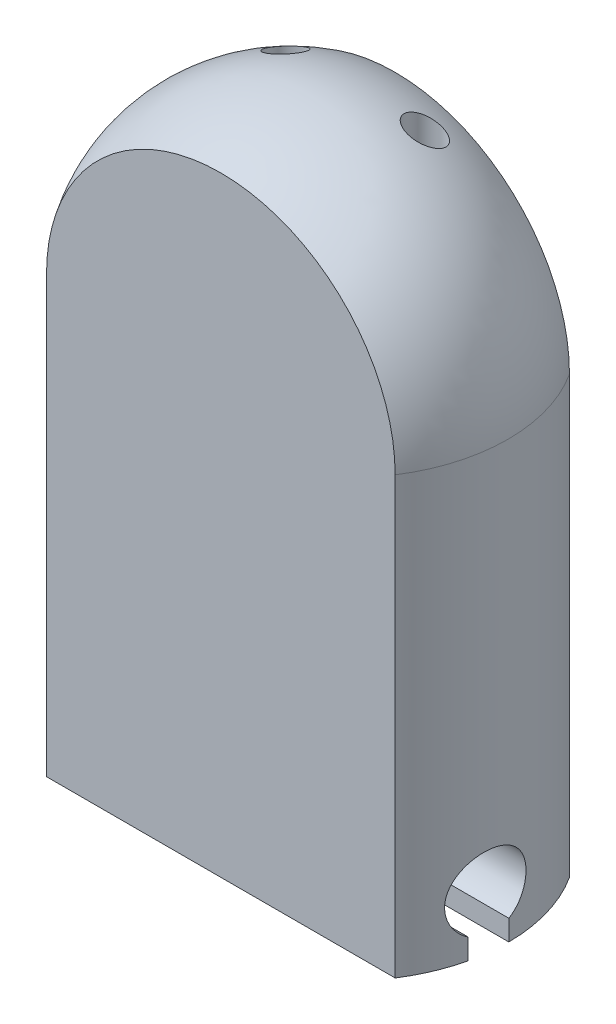
from build123d import *

# Parameters (mm, degrees)
BOSS_EXTRUDE1_DEPTH      = 10
BOSS_EXTRUDE2_DEPTH      = 25
SKETCH11_R               = 1
CUT_EXTRUDE9_DEPTH       = 40.519896768
CUT_EXTRUDE16_DEPTH      = 14.1
CUT_EXTRUDE16_DEPTH_BACK = 14.1


with BuildPart() as part:
    # Sketch1 → Boss-Extrude1 (new body)
    with BuildSketch(Plane.XY):
        with BuildLine():
            Line((10, 0), (-10, 0))
            Line((-10, 0), (-10, 25))
            ThreePointArc((-10, 25), (0, 35), (10, 25))
            Line((10, 25), (10, 0))
        make_face()
    extrude(amount=BOSS_EXTRUDE1_DEPTH)

    # Sketch16 → Boss-Extrude2 (add)
    with BuildSketch(Plane.XZ):
        with BuildLine():
            Line((-10, 0), (-10, 10))
            ThreePointArc((-10, 10), (-11.472090345, 5), (-10, 0))
        make_face()
        with BuildLine():
            Line((10, 0), (10, 10))
            ThreePointArc((10, 10), (11.472090345, 5), (10, 0))
        make_face()
    extrude(amount=-BOSS_EXTRUDE2_DEPTH)

    # Sketch18 → Revolve1 (revolve)
    with BuildSketch(Plane(origin=(0, 25, 0), x_dir=(1, 0, 0), z_dir=(0, 1, 0))):
        with BuildLine():
            Line((10, 0), (10, -10))
            ThreePointArc((10, -10), (11.472090345, -5), (10, 0))
        make_face()
    revolve(axis=Axis((0, 25, 0), (0, 0, 1)))

    # Sketch11 → Cut-Extrude9 (cut, through all)
    with BuildSketch(Plane.XZ):
        with Locations((4, 2.295920755)):
            Circle(SKETCH11_R)
        with Locations((-4, 2.295920755)):
            Circle(SKETCH11_R)
    extrude(amount=-CUT_EXTRUDE9_DEPTH, mode=Mode.SUBTRACT)

    # Sketch14 → Cut-Extrude16 (cut, two sides: drawn at the far end of the back side and taken through both)
    with BuildSketch(Plane.ZY.offset(-CUT_EXTRUDE16_DEPTH_BACK)):
        with BuildLine():
            Line((4.95, 1.181346652), (4.95, 0))
            Line((4.95, 0), (7.05, 0))
            Line((7.05, 0), (7.05, 1.181346652))
            ThreePointArc((7.05, 1.181346652), (6, 5.1), (4.95, 1.181346652))
        make_face()
    extrude(amount=CUT_EXTRUDE16_DEPTH + CUT_EXTRUDE16_DEPTH_BACK, mode=Mode.SUBTRACT)


solid = part.part
